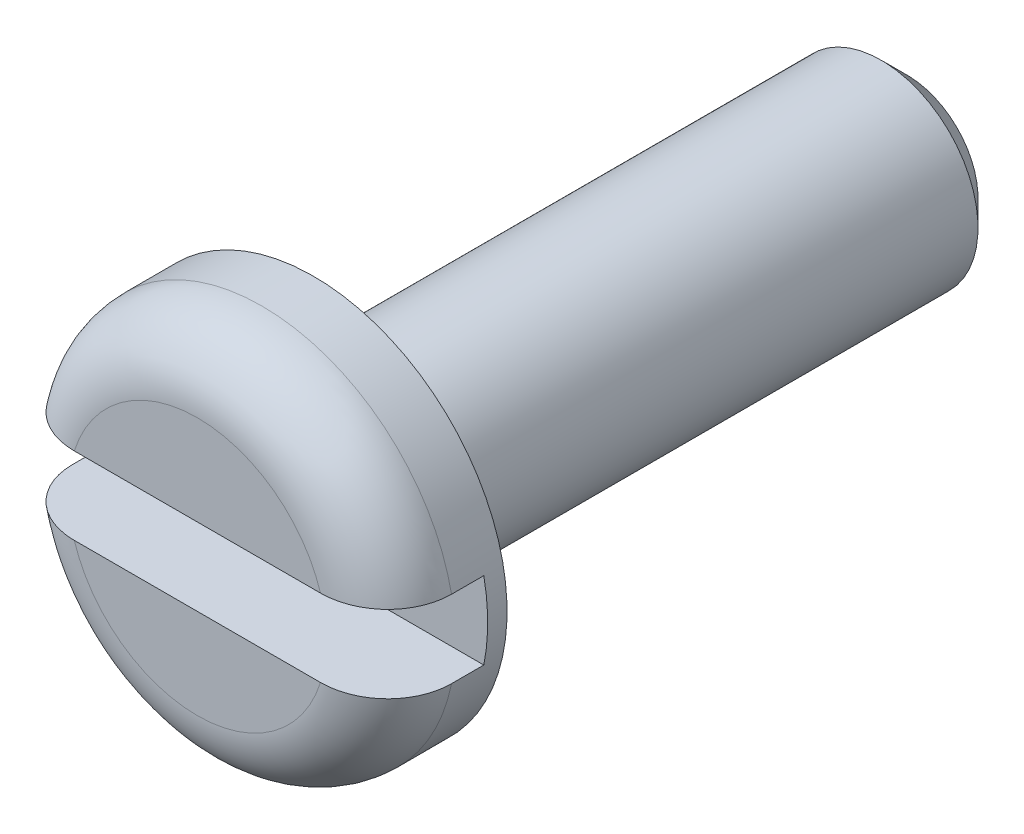
from build123d import *

# Parameters (mm, degrees)
SKETCH_2_W               = 1.5
SKETCH_2_H               = 1.2
CUT_EXTRUDE_1_DEPTH      = 4
CUT_EXTRUDE_1_DEPTH_BACK = 4
CHAMFER_1_SIZE           = 0.4
FILLET_1_R               = 1
FILLET_2_R               = 0.4


with BuildPart() as part:
    # Эскиз1 → Повернуть1 (revolve)
    with BuildSketch(Plane(origin=(0, 0, 0), x_dir=(1, 0, 0), z_dir=(0, 1, 0))):
        Polygon((0, 0), (-3, 0), (-3, 1.8), (-1.5, 1.8), (-1.5, 11), (0, 11), align=None)
    revolve(axis=Axis((0, 0, -11), (0, 0, 1)))

    # Эскиз2 → Вырез-Вытянуть1 (cut, two sides)
    with BuildSketch(Plane(origin=(0, 0, 0), x_dir=(0, 0, -1), z_dir=(1, 0, 0))) as cut_extrude_1_sk:
        with Locations((0.75, 0)):
            Rectangle(SKETCH_2_W, SKETCH_2_H)
    extrude(amount=CUT_EXTRUDE_1_DEPTH, mode=Mode.SUBTRACT)
    extrude(cut_extrude_1_sk.sketch, amount=-CUT_EXTRUDE_1_DEPTH_BACK, mode=Mode.SUBTRACT)

    # Фаска1
    chamfer_1_edges = [part.edges().sort_by_distance(p)[0] for p in [
        (1.5, 0, -11),
    ]]
    chamfer(chamfer_1_edges, length=CHAMFER_1_SIZE)

    # Скругление1
    fillet_1_edges = [part.edges().sort_by_distance(p)[0] for p in [
        (0, 3, 0),
        (0, -3, 0),
    ]]
    fillet(fillet_1_edges, radius=FILLET_1_R)

    # Скругление2
    fillet_2_edges = [part.edges().sort_by_distance(p)[0] for p in [
        (1.5, 0, -1.8),
    ]]
    fillet(fillet_2_edges, radius=FILLET_2_R)


solid = part.part
